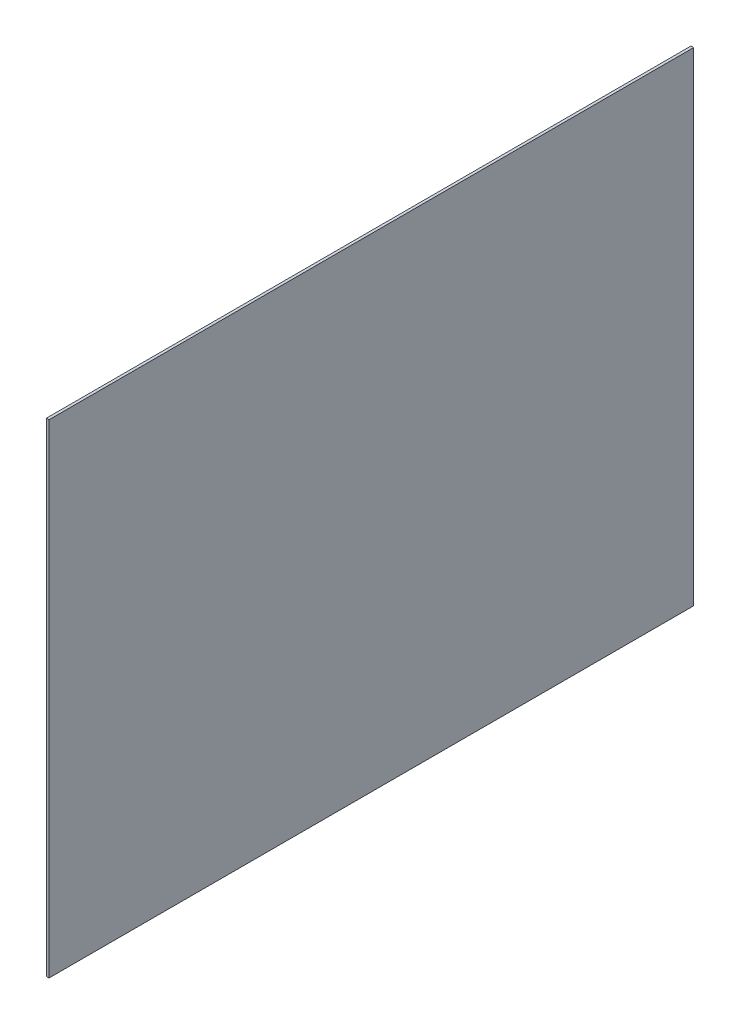
from build123d import *

# Parameters (mm, degrees)
SKETCH1_W           = 609.6
SKETCH1_H           = 457.2
BOSS_EXTRUDE1_DEPTH = 2.54


with BuildPart() as part:
    # Sketch1 → Boss-Extrude1 (new body)
    with BuildSketch(Plane(origin=(0, 0, 0), x_dir=(0, 0, -1), z_dir=(1, 0, 0))):
        Rectangle(SKETCH1_W, SKETCH1_H)
    extrude(amount=BOSS_EXTRUDE1_DEPTH)


solid = part.part
